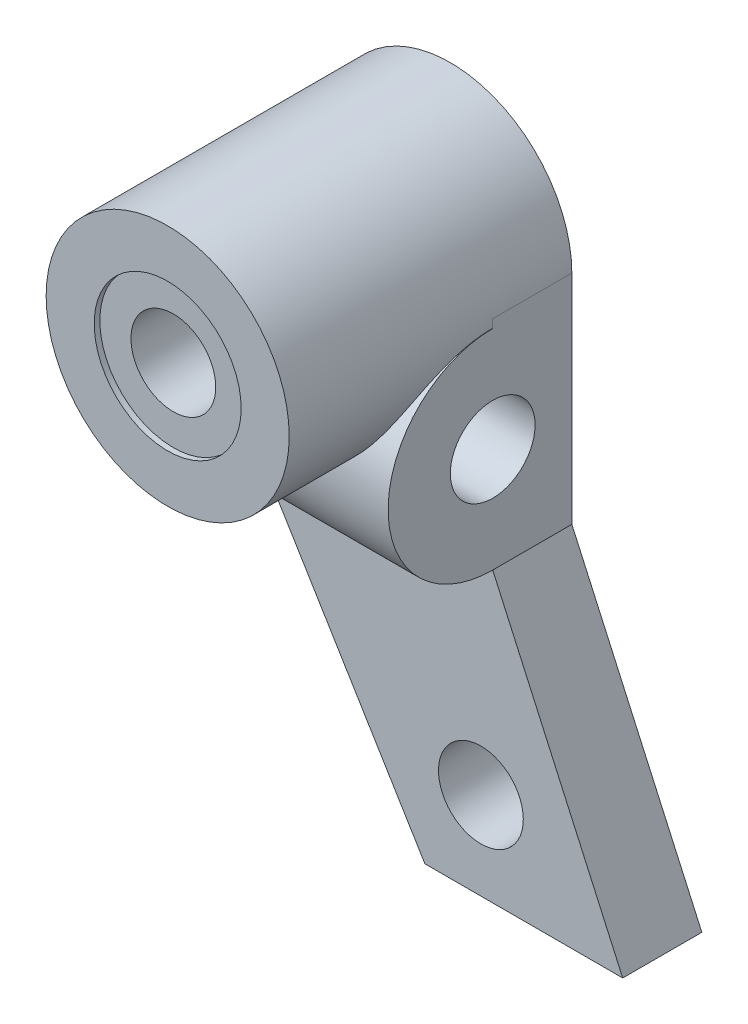
from build123d import *
from build123d.topology import SkipClean

# Parameters (mm, degrees)
SKETCH_1_R          = 1.5
EXTRUDE_1_DEPTH     = 2.8
EXTRUDE_2_DEPTH     = 9.6
SKETCH_3_R          = 4.3
SKETCH_3_R_2        = 1.5
EXTRUDE_4_DEPTH     = 10
CUT_EXTRUDE_START   = -0.2
SKETCH_4_R          = 2.6
SKETCH_4_R_2        = 1.5
CUT_EXTRUDE_1_DEPTH = 0.2
CUT_EXTRUDE_2_DEPTH = 7
SKETCH_6_R          = 1.5
CUT_EXTRUDE_3_DEPTH = 23.64000892


with BuildPart() as part:
    # 草图1 → 凸台-拉伸1 (new body)
    with BuildSketch(Plane.XY):
        with BuildLine():
            Line((4.3, -7.7), (4.3, 0))
            ThreePointArc((4.3, 0), (0, 4.3), (-4.3, 0))
            Line((-4.3, 0), (-4.3, -7.7))
            Line((-4.3, -7.7), (1.9, -17.9))
            Line((1.9, -17.9), (8.9, -17.9))
            Line((8.9, -17.9), (4.3, -7.7))
        make_face()
        Circle(SKETCH_1_R, mode=Mode.SUBTRACT)
        with Locations((3.881899419, -14.8)):
            Circle(SKETCH_1_R, mode=Mode.SUBTRACT)
    extrude(amount=EXTRUDE_1_DEPTH)

    # 草图2 → 凸台-拉伸2 (add)
    with BuildSketch(Plane(origin=(4.3, 0, 0), x_dir=(0, 0, -1), z_dir=(1, 0, 0))):
        with BuildLine():
            Line((0, -6.418677324), (0, -1.581322676))
            ThreePointArc((0, -1.581322676), (-6.5, -4), (0, -6.418677324))
        make_face()
    extrude(amount=-EXTRUDE_2_DEPTH)

    # 草图3 → 凸台-拉伸4 (add)
    with SkipClean():  # the faces are left unmerged after this step: merging them gives an invalid solid
        with BuildSketch(Plane(origin=(0, 0, 0), x_dir=(-1, 0, 0), z_dir=(0, 0, -1))):
            Circle(SKETCH_3_R)
            Circle(SKETCH_3_R_2, mode=Mode.SUBTRACT)
        extrude(amount=-EXTRUDE_4_DEPTH)

    # 草图4 → 切除-拉伸1 (cut)
    with SkipClean():  # the faces are left unmerged after this step: merging them gives an invalid solid
        with BuildSketch(Plane.XY.offset(10).offset(CUT_EXTRUDE_START)):
            Circle(SKETCH_4_R)
            Circle(SKETCH_4_R_2, mode=Mode.SUBTRACT)
        extrude(amount=CUT_EXTRUDE_1_DEPTH, mode=Mode.SUBTRACT)

    # 草图5 → 切除-拉伸2 (cut)
    with SkipClean():  # the faces are left unmerged after this step: merging them gives an invalid solid
        with BuildSketch(Plane.ZY.offset(5.3)):
            Polygon((0.8, -5.154700538), (2.8, -6.309401077), (4.8, -5.154700538), (4.8, -2.845299462), (2.8, -1.690598923), (0.8, -2.845299462), align=None)
        extrude(amount=-CUT_EXTRUDE_2_DEPTH, mode=Mode.SUBTRACT)

    # 草图6 → 切除-拉伸3 (cut, through all)
    with SkipClean():  # the faces are left unmerged after this step: merging them gives an invalid solid
        with BuildSketch(Plane(origin=(4.3, 0, 0), x_dir=(0, 0, -1), z_dir=(1, 0, 0))):
            with Locations((-2.8, -4)):
                Circle(SKETCH_6_R)
        extrude(amount=-CUT_EXTRUDE_3_DEPTH, mode=Mode.SUBTRACT)


solid = part.part
